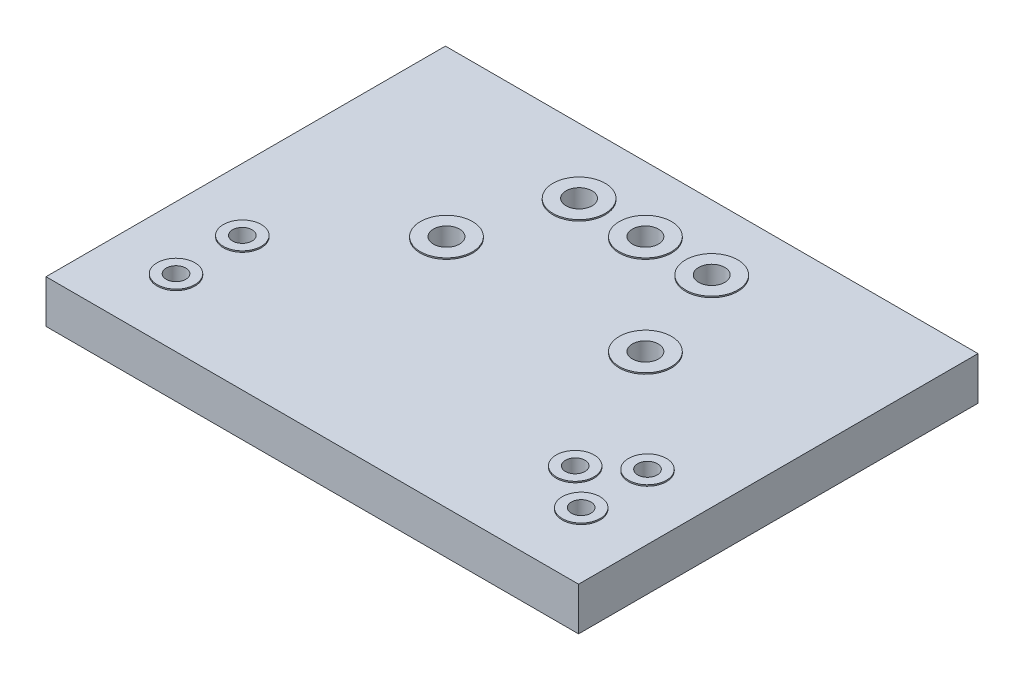
from build123d import *

# Parameters (mm, degrees)
SKETCH3_W           = 20.4
SKETCH3_H           = 15.3
SKETCH3_R           = 0.5
SKETCH3_R_2         = 0.375
BOSS_EXTRUDE2_DEPTH = 0.825
SKETCH5_R           = 1
SKETCH5_R_2         = 0.5
SKETCH5_R_3         = 0.725
SKETCH5_R_4         = 0.375
BOSS_EXTRUDE3_DEPTH = 0.05


with BuildPart() as part:
    # Sketch3 → Boss-Extrude2 (new body, symmetric)
    with BuildSketch(Plane(origin=(0, 0, 0), x_dir=(1, 0, 0), z_dir=(0, 1, 0))):
        Rectangle(SKETCH3_W, SKETCH3_H)
        with Locations((-2.54, 5.11)):
            Circle(SKETCH3_R, mode=Mode.SUBTRACT)
        with Locations((0, 5.11)):
            Circle(SKETCH3_R, mode=Mode.SUBTRACT)
        with Locations((2.54, 5.11)):
            Circle(SKETCH3_R, mode=Mode.SUBTRACT)
        with Locations((-7.76, -2.57)):
            Circle(SKETCH3_R_2, mode=Mode.SUBTRACT)
        with Locations((-7.76, -5.11)):
            Circle(SKETCH3_R_2, mode=Mode.SUBTRACT)
        with Locations((7.76, -2.57)):
            Circle(SKETCH3_R_2, mode=Mode.SUBTRACT)
        with Locations((7.76, -5.11)):
            Circle(SKETCH3_R_2, mode=Mode.SUBTRACT)
        with Locations((6.260003, -3.84)):
            Circle(SKETCH3_R_2, mode=Mode.SUBTRACT)
        with Locations((-3.81, 1.3)):
            Circle(SKETCH3_R, mode=Mode.SUBTRACT)
        with Locations((3.81, 1.3)):
            Circle(SKETCH3_R, mode=Mode.SUBTRACT)
    extrude(amount=BOSS_EXTRUDE2_DEPTH, both=True)

    # Sketch5 → Boss-Extrude3 (add)
    with BuildSketch(Plane(origin=(0, 0.825, 0), x_dir=(1, 0, 0), z_dir=(0, 1, 0))):
        with Locations((-2.54, 5.11)):
            Circle(SKETCH5_R)
        with Locations((-2.54, 5.11)):
            Circle(SKETCH5_R_2, mode=Mode.SUBTRACT)
        with Locations((0, 5.11)):
            Circle(SKETCH5_R)
        with Locations((0, 5.11)):
            Circle(SKETCH5_R_2, mode=Mode.SUBTRACT)
        with Locations((2.54, 5.11)):
            Circle(SKETCH5_R)
        with Locations((2.54, 5.11)):
            Circle(SKETCH5_R_2, mode=Mode.SUBTRACT)
        with Locations((3.81, 1.3)):
            Circle(SKETCH5_R)
        with Locations((3.81, 1.3)):
            Circle(SKETCH5_R_2, mode=Mode.SUBTRACT)
        with Locations((-3.81, 1.3)):
            Circle(SKETCH5_R)
        with Locations((-3.81, 1.3)):
            Circle(SKETCH5_R_2, mode=Mode.SUBTRACT)
        with Locations((-7.76, -2.57)):
            Circle(SKETCH5_R_3)
        with Locations((-7.76, -2.57)):
            Circle(SKETCH5_R_4, mode=Mode.SUBTRACT)
        with Locations((-7.76, -5.11)):
            Circle(SKETCH5_R_3)
        with Locations((-7.76, -5.11)):
            Circle(SKETCH5_R_4, mode=Mode.SUBTRACT)
        with Locations((6.260003, -3.84)):
            Circle(SKETCH5_R_3)
        with Locations((6.260003, -3.84)):
            Circle(SKETCH5_R_4, mode=Mode.SUBTRACT)
        with Locations((7.76, -5.11)):
            Circle(SKETCH5_R_3)
        with Locations((7.76, -5.11)):
            Circle(SKETCH5_R_4, mode=Mode.SUBTRACT)
        with Locations((7.76, -2.57)):
            Circle(SKETCH5_R_3)
        with Locations((7.76, -2.57)):
            Circle(SKETCH5_R_4, mode=Mode.SUBTRACT)
    boss_extrude3 = extrude(amount=BOSS_EXTRUDE3_DEPTH)

    # Mirror1: Boss-Extrude3 across plane
    add(boss_extrude3.mirror(Plane.ZX))


solid = part.part
